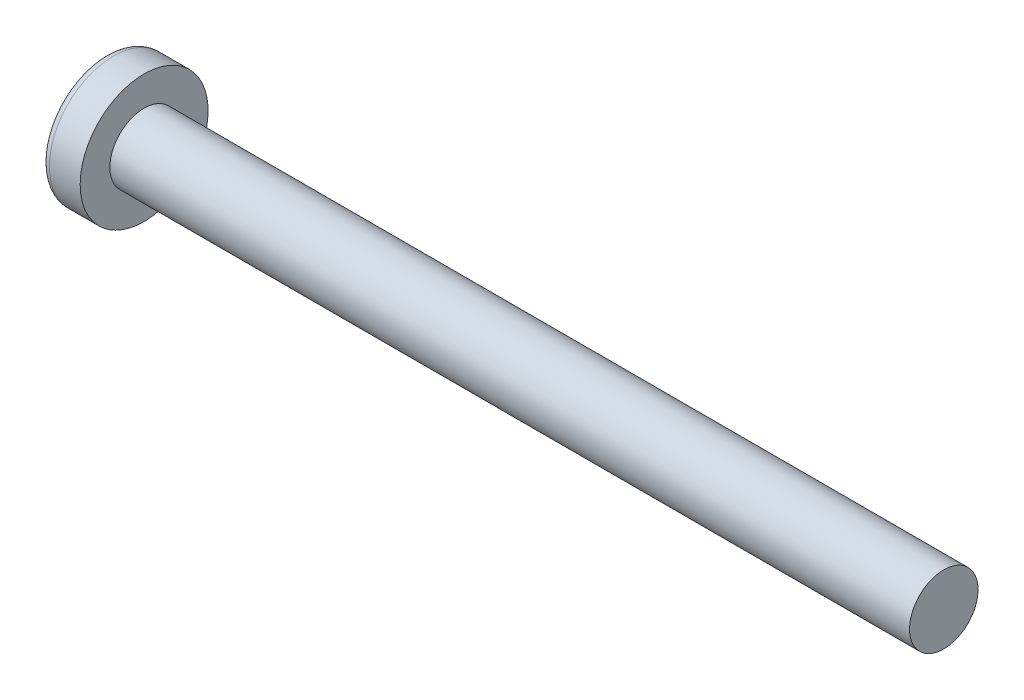
from build123d import *

# Parameters (mm, degrees)
SKETCH3_W         = 0.74
SKETCH3_H         = 2.9
SKETCH4_W         = 0.37
SKETCH4_H         = 0.37
CIRPATTERN1_COUNT = 2
CIRPATTERN1_ANGLE = 90


with BuildPart() as part:
    # BodySke → Base-Revolve (revolve)
    with BuildSketch(Plane.XY):
        with BuildLine():
            Line((2.4, 1.5), (2.4, 2.8))
            Line((2.4, 2.8), (1.053355856, 2.8))
            ThreePointArc((1.053355856, 2.8), (0.878072834, 2.754445324), (0.747150707, 2.629310345))
            ThreePointArc((0.747150707, 2.629310345), (0.190413403, 1.366702882), (0, 0))
            Line((0, 0), (37.4, 0))
            Line((37.4, 0), (37.4, 1.5))
            Line((37.4, 1.5), (2.4, 1.5))
        make_face()
    revolve(axis=Axis((-25.4, 0, 0), (1, 0, 0)))

    # Sketch3 → Cut-Loft1 section 0
    with BuildSketch(Plane(origin=(0, 0, 0), x_dir=(0, 0, -1), z_dir=(1, 0, 0))):
        Rectangle(SKETCH3_W, SKETCH3_H)
    # Sketch4 → Cut-Loft1 section 1
    with BuildSketch(Plane(origin=(1.76, 0, 0), x_dir=(0, 0, -1), z_dir=(1, 0, 0))):
        Rectangle(SKETCH4_W, SKETCH4_H)
    cut_loft1 = loft(mode=Mode.SUBTRACT)

    # CirPattern1: Cut-Loft1 ×2 about axis
    cirpattern1_axis = Axis((-25.4, 0, 0), (1, 0, 0))
    for i in range(1, CIRPATTERN1_COUNT):
        add(cut_loft1.rotate(cirpattern1_axis, i * CIRPATTERN1_ANGLE / (CIRPATTERN1_COUNT - 1)), mode=Mode.SUBTRACT)


solid = part.part
